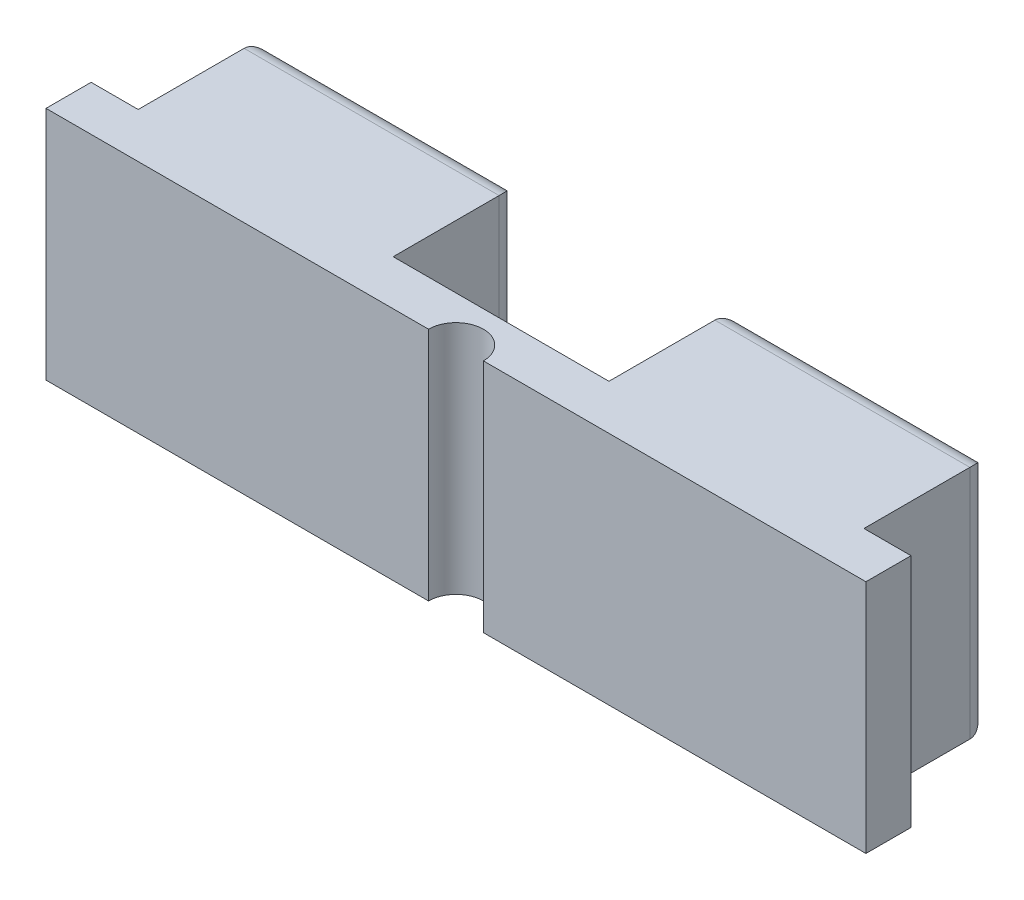
from build123d import *

# Parameters (mm, degrees)
EXTRUDE_1_DEPTH     = 6
SKETCH_2_W          = 1.8
SKETCH_2_H          = 0.5
SKETCH_2_W_2        = 1
SKETCH_2_H_2        = 1.3
SKETCH_2_W_3        = 1.3
SKETCH_2_W_4        = 0.5
CUT_EXTRUDE_1_DEPTH = 0.5
FILLET_1_R          = 0.5


with BuildPart() as part:
    # 草图1 → 凸台-拉伸1 (new body)
    with BuildSketch(Plane(origin=(0, 0, 0), x_dir=(1, 0, 0), z_dir=(0, 1, 0))):
        with BuildLine():
            Line((-153.747698535, 92.341311307), (-153.747698535, 90.141311307))
            Line((-153.747698535, 90.141311307), (-154.947698535, 90.141311307))
            Line((-154.947698535, 90.141311307), (-154.947698535, 89.341311307))
            Line((-154.947698535, 89.341311307), (-154.947698535, 88.991311307))
            Line((-154.947698535, 88.991311307), (-145.197698535, 88.991311307))
            ThreePointArc((-145.197698535, 88.991311307), (-144.497698535, 89.691311307), (-143.797698535, 88.991311307))
            Line((-143.797698535, 88.991311307), (-134.047698535, 88.991311307))
            Line((-134.047698535, 88.991311307), (-134.047698535, 89.341311307))
            Line((-134.047698535, 89.341311307), (-134.047698535, 90.141311307))
            Line((-134.047698535, 90.141311307), (-135.247698535, 90.141311307))
            Line((-135.247698535, 90.141311307), (-135.247698535, 93.341311307))
            Line((-135.247698535, 93.341311307), (-141.747698535, 93.341311307))
            Line((-141.747698535, 93.341311307), (-141.747698535, 90.141311307))
            Line((-141.747698535, 90.141311307), (-141.997698535, 90.141311307))
            Line((-141.997698535, 90.141311307), (-147.247698535, 90.141311307))
            Line((-147.247698535, 90.141311307), (-147.247698535, 93.341311307))
            Line((-147.247698535, 93.341311307), (-153.747698535, 93.341311307))
            Line((-153.747698535, 93.341311307), (-153.747698535, 92.341311307))
        make_face()
    extrude(amount=EXTRUDE_1_DEPTH)

    # 草图2 → 切除-拉伸1 (cut)
    with BuildSketch(Plane(origin=(0, 0, -93.341311307), x_dir=(-1, 0, 0), z_dir=(0, 0, -1))):
        Polygon((148.697698535, 3.5), (148.697698535, 3), (150.497698535, 3), (152.297698535, 3), (152.297698535, 3.5), align=None)
        with Locations((151.397698535, 2.75)):
            Rectangle(SKETCH_2_W, SKETCH_2_H)
        with Locations((149.597698535, 2.75)):
            Rectangle(SKETCH_2_W, SKETCH_2_H)
        with Locations((138.497698535, 4.15)):
            Rectangle(SKETCH_2_W_2, SKETCH_2_H_2)
        with Locations((137.347698535, 3.25)):
            Rectangle(SKETCH_2_W_3, SKETCH_2_H)
        Polygon((137.997698535, 3.5), (137.997698535, 3), (138.497698535, 3), (138.997698535, 3), (138.997698535, 3.5), align=None)
        with Locations((139.647698535, 3.25)):
            Rectangle(SKETCH_2_W_3, SKETCH_2_H)
        with Locations((139.647698535, 2.75)):
            Rectangle(SKETCH_2_W_3, SKETCH_2_H)
        with Locations((138.747698535, 2.75)):
            Rectangle(SKETCH_2_W_4, SKETCH_2_H)
        with Locations((138.247698535, 2.75)):
            Rectangle(SKETCH_2_W_4, SKETCH_2_H)
        with Locations((137.347698535, 2.75)):
            Rectangle(SKETCH_2_W_3, SKETCH_2_H)
        with Locations((138.247698535, 1.85)):
            Rectangle(SKETCH_2_W_4, SKETCH_2_H_2)
        with Locations((138.747698535, 1.85)):
            Rectangle(SKETCH_2_W_4, SKETCH_2_H_2)
    extrude(amount=-CUT_EXTRUDE_1_DEPTH, mode=Mode.SUBTRACT)

    # 圆角1
    fillet_1_edges = [part.edges().sort_by_distance(p)[0] for p in [
        (-150.497698535, 0, -93.341311307),
        (-138.497698535, 0, -93.341311307),
        (-138.497698535, 6, -93.341311307),
        (-153.747698535, 3, -93.341311307),
        (-147.247698535, 3, -93.341311307),
        (-141.747698535, 3, -93.341311307),
        (-135.247698535, 3, -93.341311307),
        (-150.497698535, 6, -93.341311307),
    ]]
    fillet(fillet_1_edges, radius=FILLET_1_R)


solid = part.part
